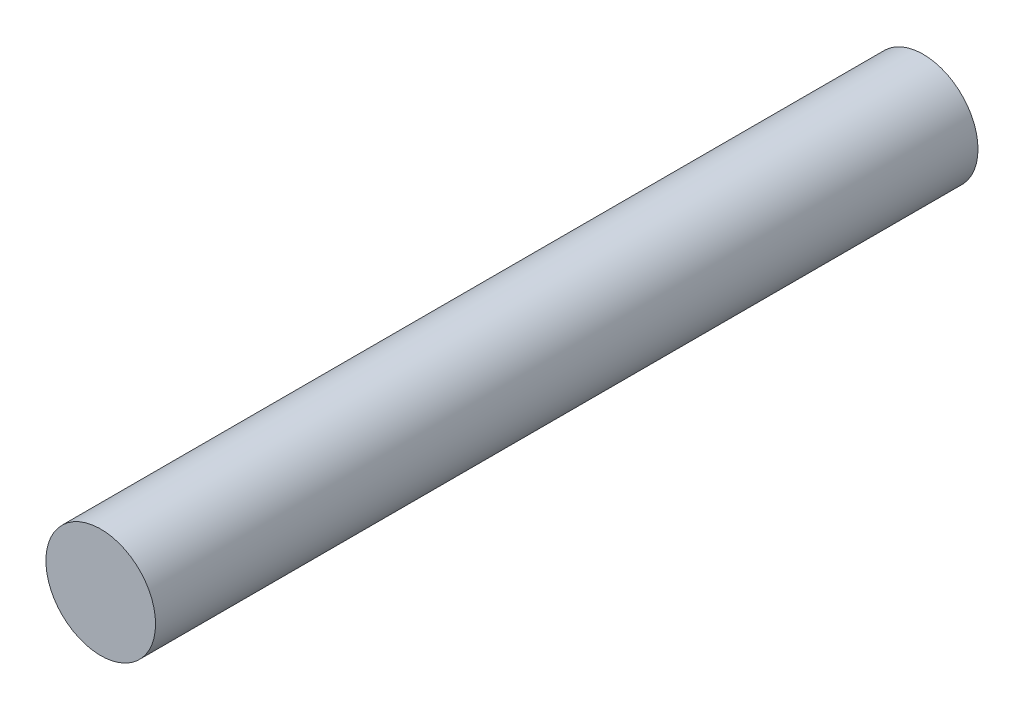
from build123d import *

# Parameters (mm, degrees)
SKETCH1_R           = 2
BOSS_EXTRUDE1_DEPTH = 30


with BuildPart() as part:
    # Sketch1 → Boss-Extrude1 (new body)
    with BuildSketch(Plane.XY):
        Circle(SKETCH1_R)
    extrude(amount=BOSS_EXTRUDE1_DEPTH)


solid = part.part
